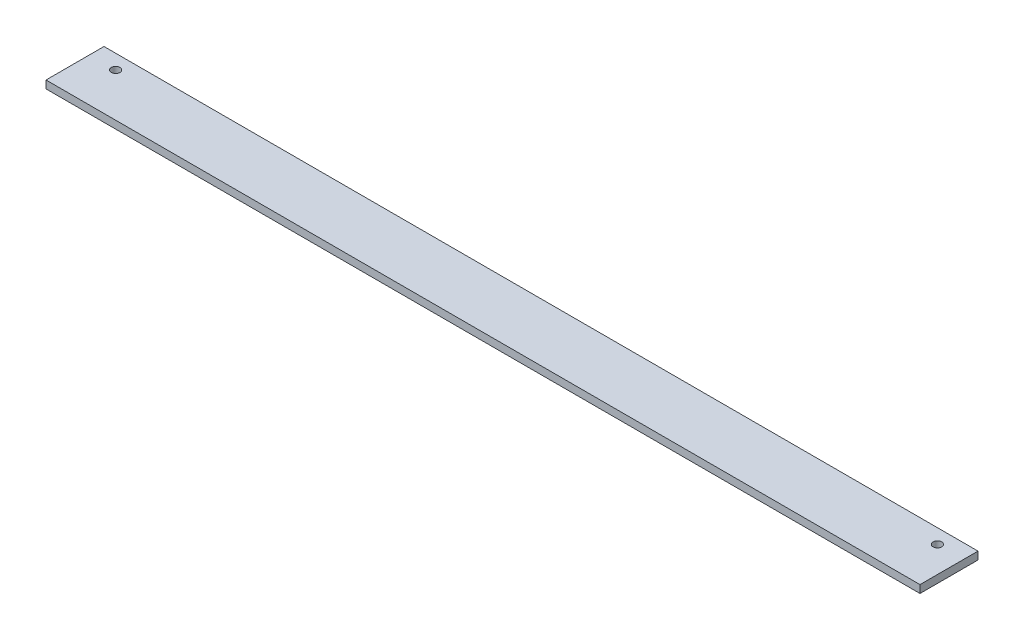
from build123d import *

# Parameters (mm, degrees)
SKETCH_1_W          = 30
SKETCH_1_H          = 4
EXTRUDE_1_DEPTH     = 452
SKETCH_2_R          = 2.25
CUT_EXTRUDE_1_DEPTH = 5


with BuildPart() as part:
    # Эскиз1 → Бобышка-Вытянуть1 (new body)
    with BuildSketch(Plane(origin=(0, 0, 0), x_dir=(0, 0, -1), z_dir=(1, 0, 0))):
        Rectangle(SKETCH_1_W, SKETCH_1_H)
    extrude(amount=EXTRUDE_1_DEPTH)

    # Эскиз2 → Вырез-Вытянуть1 (cut, through all)
    with BuildSketch(Plane(origin=(0, 2, 0), x_dir=(1, 0, 0), z_dir=(0, 1, 0))):
        with Locations((13.5, 7.5)):
            Circle(SKETCH_2_R)
        with Locations((438.5, 7.5)):
            Circle(SKETCH_2_R)
    extrude(amount=-CUT_EXTRUDE_1_DEPTH, mode=Mode.SUBTRACT)


solid = part.part
